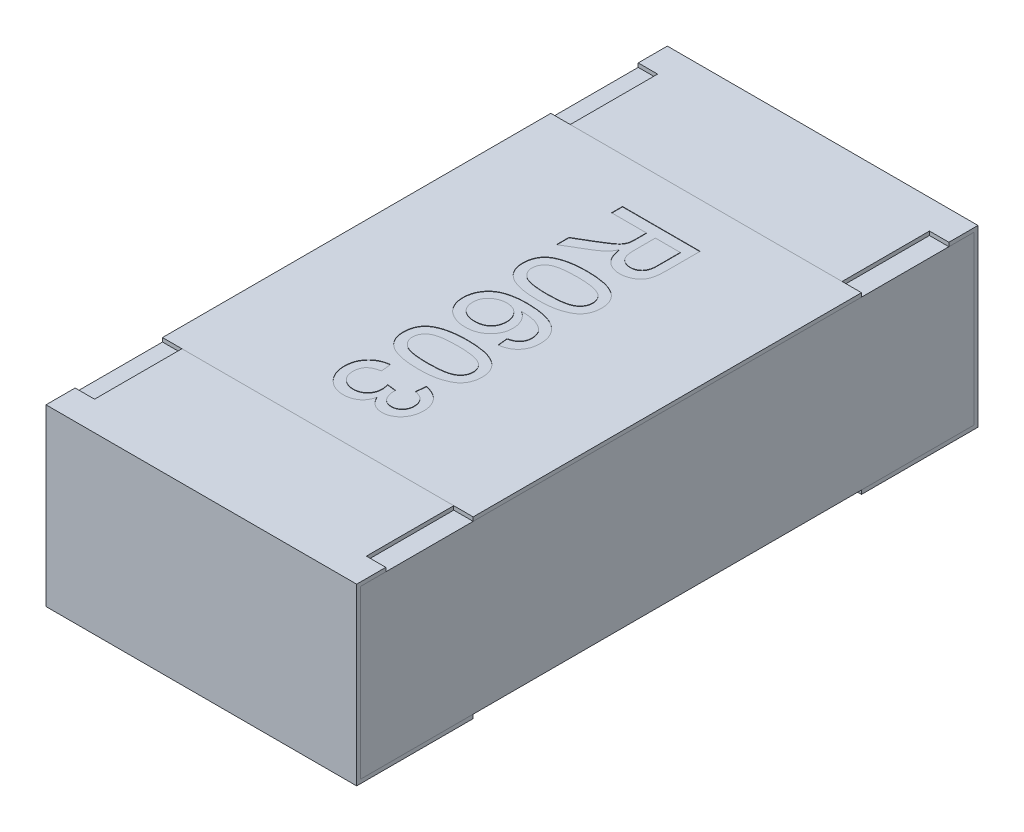
from build123d import *

# Parameters (mm, degrees)
BOSS_EXTRUDE2_DEPTH   = 0.4
BOSS_EXTRUDE2_2_DEPTH = 0.4
BOSS_EXTRUDE3_START   = -0.4
SKETCH5_W             = 1.58
SKETCH5_H             = 0.43
BOSS_EXTRUDE3_DEPTH   = 0.8
SKETCH6_W             = 0.05
SKETCH6_H             = 0.225
CUT_EXTRUDE1_DEPTH    = 0.01
SKETCH7_W             = 0.8
SKETCH7_H             = 1
BOSS_EXTRUDE4_DEPTH   = 0.01
TEXT0603_DEPTH        = 0.001


with BuildPart() as part:
    # Sketch4 → Boss-Extrude2 (new body, symmetric)
    with BuildSketch(Plane(origin=(0, 0, 0), x_dir=(0, 0, -1), z_dir=(1, 0, 0))):
        Polygon((-0.8, 0.225), (-0.8, -0.225), (-0.5, -0.225), (-0.5, -0.215), (-0.79, -0.215), (-0.79, 0.215), (-0.5, 0.215), (-0.5, 0.225), align=None)
    extrude(amount=BOSS_EXTRUDE2_DEPTH, both=True)


with BuildPart() as body_2:
    # Sketch4 → Boss-Extrude2 2 (new body, symmetric)
    with BuildSketch(Plane(origin=(0, 0, 0), x_dir=(0, 0, -1), z_dir=(1, 0, 0))):
        Polygon((0.5, 0.225), (0.8, 0.225), (0.8, -0.225), (0.5, -0.225), (0.5, -0.215), (0.79, -0.215), (0.79, 0.215), (0.5, 0.215), align=None)
    extrude(amount=BOSS_EXTRUDE2_2_DEPTH, both=True)


with BuildPart() as body_3:
    # Sketch5 → Boss-Extrude3 (new body)
    with BuildSketch(Plane(origin=(0, 0, 0), x_dir=(0, 0, -1), z_dir=(1, 0, 0)).offset(BOSS_EXTRUDE3_START)):
        Rectangle(SKETCH5_W, SKETCH5_H)
    extrude(amount=BOSS_EXTRUDE3_DEPTH)


with BuildPart() as cut_extrude1_tool:
    # Sketch6 → Cut-Extrude1 (new body)
    with BuildSketch(Plane(origin=(0, 0.225, 0), x_dir=(1, 0, 0), z_dir=(0, 1, 0))):
        with Locations((-0.375, 0.6125)):
            Rectangle(SKETCH6_W, SKETCH6_H)
        with Locations((0.375, 0.6125)):
            Rectangle(SKETCH6_W, SKETCH6_H)
        with Locations((0.375, -0.6125)):
            Rectangle(SKETCH6_W, SKETCH6_H)
        with Locations((-0.375, -0.6125)):
            Rectangle(SKETCH6_W, SKETCH6_H)
    extrude(amount=-CUT_EXTRUDE1_DEPTH)


with BuildPart() as part_1:
    add(part.part)

    # Cut-Extrude1: cut by cut_extrude1_tool
    add(cut_extrude1_tool.part, mode=Mode.SUBTRACT)


with BuildPart() as body_2_1:
    add(body_2.part)

    # Cut-Extrude1: cut by cut_extrude1_tool
    add(cut_extrude1_tool.part, mode=Mode.SUBTRACT)


with BuildPart() as body_4:
    # Sketch7 → Boss-Extrude4 (new body)
    with BuildSketch(Plane(origin=(0, 0.215, 0), x_dir=(1, 0, 0), z_dir=(0, 1, 0))):
        Rectangle(SKETCH7_W, SKETCH7_H)
    extrude(amount=BOSS_EXTRUDE4_DEPTH)

    # Sketch10 → TEXT0603 (cut)
    with BuildSketch(Plane(origin=(0, 0.225, 0), x_dir=(1, 0, 0), z_dir=(0, 1, 0))):
        with BuildLine():
            Line((-0.1, 0.384615385), (0.1, 0.384615385))
            Line((0.1, 0.384615385), (0.1, 0.297836538))
            add(Edge.make_bspline(
                [(0.1, 0.297836538), (0.099984065, 0.295793153), (0.099953225, 0.291838418), (0.09973285, 0.286103396), (0.099264662, 0.280762976), (0.098741754, 0.2757835), (0.09796967, 0.27117349), (0.097063877, 0.266930747), (0.095993333, 0.263071546), (0.094727909, 0.259566517), (0.09329673, 0.256314363), (0.09152995, 0.253300671), (0.089597129, 0.250396276), (0.087307981, 0.247716073), (0.084846527, 0.245142742), (0.082091084, 0.242764219), (0.079080565, 0.240568895), (0.074776604, 0.237860062), (0.069015312, 0.235009752), (0.061680333, 0.232577019), (0.053991505, 0.231021652), (0.048738791, 0.230854194), (0.046073718, 0.230769231)],
                knots=[0, 0, 0, 0, 6.13e-06, 1.1865e-05, 1.7211e-05, 2.2211e-05, 2.6881e-05, 3.1226e-05, 3.5222e-05, 3.8884e-05, 4.2399e-05, 4.5862e-05, 4.9352e-05, 5.285e-05, 5.642e-05, 6.0027e-05, 6.3753e-05, 6.7588e-05, 7.5275e-05, 8.2965e-05, 9.072e-05, 9.8707e-05, 9.8707e-05, 9.8707e-05, 9.8707e-05], degree=3))
            add(Edge.make_bspline(
                [(0.046073718, 0.230769231), (0.044362886, 0.230808368), (0.040983876, 0.230885665), (0.036015821, 0.231477767), (0.031269065, 0.232549148), (0.026701941, 0.23392291), (0.022379506, 0.235803447), (0.018212175, 0.237980986), (0.014319265, 0.240682401), (0.010571159, 0.243698869), (0.007135151, 0.247205721), (0.00396506, 0.251109408), (0.001226184, 0.25550818), (-0.001235186, 0.260321091), (-0.003389054, 0.265556874), (-0.005200005, 0.271250346), (-0.006617793, 0.277381347), (-0.007327988, 0.281633046), (-0.007692308, 0.283814103)],
                knots=[0, 0, 0, 0, 5.132e-06, 1.0136e-05, 1.4977e-05, 1.9717e-05, 2.442e-05, 2.9098e-05, 3.3798e-05, 3.861e-05, 4.3511e-05, 4.8498e-05, 5.3667e-05, 5.9024e-05, 6.4701e-05, 7.0631e-05, 7.6928e-05, 8.3561e-05, 8.3561e-05, 8.3561e-05, 8.3561e-05], degree=3))
            add(Edge.make_bspline(
                [(-0.007692308, 0.283814103), (-0.008502515, 0.282201955), (-0.010035947, 0.279150736), (-0.012497756, 0.274942107), (-0.014933997, 0.271328075), (-0.016715461, 0.26924351), (-0.017548077, 0.268269231)],
                knots=[0, 0, 0, 0, 5.411e-06, 1.0242e-05, 1.4621e-05, 1.8463e-05, 1.8463e-05, 1.8463e-05, 1.8463e-05], degree=3))
            add(Edge.make_bspline(
                [(-0.017548077, 0.268269231), (-0.019397609, 0.266376698), (-0.023190694, 0.262495425), (-0.029711346, 0.257198922), (-0.036882196, 0.251958094), (-0.042107727, 0.248811611), (-0.044791667, 0.247195513)],
                knots=[0, 0, 0, 0, 7.932e-06, 1.6268e-05, 2.5164e-05, 3.4558e-05, 3.4558e-05, 3.4558e-05, 3.4558e-05], degree=3))
            Line((-0.044791667, 0.247195513), (-0.1, 0.214383013))
            Line((-0.1, 0.214383013), (-0.1, 0.246714744))
            Line((-0.1, 0.246714744), (-0.057772436, 0.271634615))
            add(Edge.make_bspline(
                [(-0.057772436, 0.271634615), (-0.056290856, 0.272530646), (-0.053419797, 0.274267005), (-0.049226345, 0.27677451), (-0.045367087, 0.27923526), (-0.041725057, 0.281510108), (-0.03839495, 0.283720739), (-0.035277423, 0.285743012), (-0.032495712, 0.287732518), (-0.029145459, 0.29004634), (-0.025498969, 0.292835986), (-0.02177642, 0.296113346), (-0.018736859, 0.29915438), (-0.015800487, 0.302959128), (-0.013064385, 0.307680303), (-0.011792823, 0.311685061), (-0.011177885, 0.313621795)],
                knots=[0, 0, 0, 0, 5.194e-06, 1.0066e-05, 1.4657e-05, 1.8925e-05, 2.2947e-05, 2.6648e-05, 3.0071e-05, 3.3206e-05, 3.8863e-05, 4.383e-05, 4.808e-05, 5.1735e-05, 5.823e-05, 6.4312e-05, 6.4312e-05, 6.4312e-05, 6.4312e-05], degree=3))
            add(Edge.make_bspline(
                [(-0.011177885, 0.313621795), (-0.011031283, 0.314434737), (-0.010696589, 0.316290709), (-0.010477999, 0.319442145), (-0.010245995, 0.323260496), (-0.010252755, 0.32602772), (-0.01025641, 0.327524038)],
                knots=[0, 0, 0, 0, 2.477e-06, 5.654e-06, 9.465e-06, 1.3953e-05, 1.3953e-05, 1.3953e-05, 1.3953e-05], degree=3))
            Line((-0.01025641, 0.327524038), (-0.01025641, 0.356410256))
            Line((-0.01025641, 0.356410256), (-0.1, 0.356410256))
            Line((-0.1, 0.356410256), (-0.1, 0.384615385))
        make_face()
        with BuildLine():
            Line((0.012820513, 0.356410256), (0.012820513, 0.302844551))
            add(Edge.make_bspline(
                [(0.012820513, 0.302844551), (0.012862706, 0.300158599), (0.012941582, 0.295137464), (0.013610378, 0.288115682), (0.014684826, 0.282120684), (0.01622688, 0.277040573), (0.01837747, 0.272774838), (0.021049498, 0.269110171), (0.024300639, 0.26599257), (0.028039024, 0.26344463), (0.032117992, 0.261437809), (0.036432982, 0.260067832), (0.04089065, 0.259113377), (0.04393186, 0.259021109), (0.045472756, 0.258974359)],
                knots=[0, 0, 0, 0, 8.056e-06, 1.5061e-05, 2.1135e-05, 2.6305e-05, 3.0927e-05, 3.5399e-05, 3.9847e-05, 4.437e-05, 4.8921e-05, 5.3432e-05, 5.7926e-05, 6.2542e-05, 6.2542e-05, 6.2542e-05, 6.2542e-05], degree=3))
            add(Edge.make_bspline(
                [(0.045472756, 0.258974359), (0.046595386, 0.259011584), (0.048794286, 0.259084498), (0.052021662, 0.259466736), (0.055088415, 0.260209898), (0.058010756, 0.261191241), (0.060767282, 0.262502515), (0.063379352, 0.264060255), (0.065832489, 0.265919119), (0.068134166, 0.268048342), (0.070228467, 0.270493076), (0.072035395, 0.273285537), (0.073570893, 0.276403701), (0.074789568, 0.279851192), (0.075764309, 0.283617151), (0.076412773, 0.287723015), (0.076881999, 0.292150008), (0.076909128, 0.295217658), (0.076923077, 0.296794872)],
                knots=[0, 0, 0, 0, 3.369e-06, 6.599e-06, 9.728e-06, 1.282e-05, 1.5831e-05, 1.8868e-05, 2.1929e-05, 2.5047e-05, 2.8258e-05, 3.1559e-05, 3.4999e-05, 3.8661e-05, 4.2509e-05, 4.6652e-05, 5.1121e-05, 5.585e-05, 5.585e-05, 5.585e-05, 5.585e-05], degree=3))
            Line((0.076923077, 0.296794872), (0.076923077, 0.356410256))
            Line((0.076923077, 0.356410256), (0.012820513, 0.356410256))
        make_face(mode=Mode.SUBTRACT)
        with BuildLine():
            add(Edge.make_bspline(
                [(-0.001362179, 0.194871795), (0.001496004, 0.194845962), (0.007093982, 0.194795365), (0.01528483, 0.194481531), (0.023063338, 0.1939336), (0.030422754, 0.193115695), (0.03737968, 0.192147128), (0.043924224, 0.190888035), (0.050070943, 0.189471208), (0.055813865, 0.187771845), (0.061200859, 0.185902848), (0.066228535, 0.183789277), (0.070867156, 0.181390323), (0.075242692, 0.178922309), (0.079150183, 0.17604891), (0.082837127, 0.173134938), (0.086093066, 0.169882364), (0.089024575, 0.166445884), (0.091610645, 0.162768544), (0.093842323, 0.158871465), (0.095812677, 0.1547692), (0.097295972, 0.150383684), (0.098505168, 0.145805926), (0.099394669, 0.1410007), (0.099919059, 0.135962707), (0.099972715, 0.132519946), (0.1, 0.130769231)],
                knots=[0, 0, 0, 0, 8.575e-06, 1.6794e-05, 2.4587e-05, 3.1962e-05, 3.9005e-05, 4.5652e-05, 5.1949e-05, 5.7921e-05, 6.361e-05, 6.9049e-05, 7.4263e-05, 7.9273e-05, 8.4098e-05, 8.8797e-05, 9.3358e-05, 9.7877e-05, 0.000102335, 0.000106822, 0.000111338, 0.000115963, 0.000120686, 0.000125534, 0.000130609, 0.00013586, 0.00013586, 0.00013586, 0.00013586], degree=3))
            add(Edge.make_bspline(
                [(0.1, 0.130769231), (0.09992442, 0.128200749), (0.099775939, 0.123154864), (0.098566996, 0.115787062), (0.096493798, 0.108846366), (0.093718792, 0.102333863), (0.090129104, 0.096390371), (0.085877537, 0.091016901), (0.080786087, 0.086430566), (0.07502184, 0.082479866), (0.068573352, 0.079092141), (0.061501351, 0.076061682), (0.053775857, 0.073344593), (0.046880048, 0.071355802), (0.040917257, 0.069961484), (0.035990018, 0.069112583), (0.030689821, 0.068328803), (0.025003973, 0.067773248), (0.01895905, 0.067207926), (0.012528692, 0.06692882), (0.005717266, 0.06671582), (0.001041875, 0.066683358), (-0.001362179, 0.066666667)],
                knots=[0, 0, 0, 0, 7.703e-06, 1.5132e-05, 2.232e-05, 2.939e-05, 3.6309e-05, 4.3092e-05, 4.987e-05, 5.6782e-05, 6.4006e-05, 7.1686e-05, 7.9847e-05, 8.8558e-05, 9.3204e-05, 9.821e-05, 0.000103553, 0.000109274, 0.000115346, 0.000121764, 0.000128578, 0.00013579, 0.00013579, 0.00013579, 0.00013579], degree=3))
            add(Edge.make_bspline(
                [(-0.001362179, 0.066666667), (-0.00420696, 0.066692838), (-0.009764799, 0.06674397), (-0.017889658, 0.067051418), (-0.02561058, 0.067625242), (-0.032936981, 0.068364698), (-0.039875654, 0.069360281), (-0.046409619, 0.070604646), (-0.052546889, 0.07204189), (-0.058293654, 0.073668328), (-0.063657824, 0.07556057), (-0.06866507, 0.07769477), (-0.073364456, 0.079983262), (-0.07766846, 0.082579034), (-0.081648328, 0.085343686), (-0.085316591, 0.088303046), (-0.088621112, 0.091518412), (-0.09154299, 0.094986969), (-0.094175564, 0.098638059), (-0.096427535, 0.102545265), (-0.098306244, 0.106699448), (-0.099876447, 0.111063583), (-0.10106977, 0.115666638), (-0.10195578, 0.120484629), (-0.102484984, 0.125548988), (-0.102537366, 0.129005142), (-0.102564103, 0.130769231)],
                knots=[0, 0, 0, 0, 8.535e-06, 1.6674e-05, 2.4387e-05, 3.1758e-05, 3.8761e-05, 4.5408e-05, 5.1705e-05, 5.7665e-05, 6.3317e-05, 6.8757e-05, 7.3988e-05, 7.8984e-05, 8.3818e-05, 8.8517e-05, 9.3107e-05, 9.7627e-05, 0.000102107, 0.000106594, 0.00011113, 0.000115768, 0.000120491, 0.000125379, 0.000130454, 0.000135745, 0.000135745, 0.000135745, 0.000135745], degree=3))
            add(Edge.make_bspline(
                [(-0.102564103, 0.130769231), (-0.102498128, 0.133082104), (-0.102369495, 0.13759157), (-0.101495515, 0.144177313), (-0.099957268, 0.150358384), (-0.097894263, 0.156186917), (-0.095134874, 0.161597397), (-0.091777539, 0.166615658), (-0.087900369, 0.171342538), (-0.084841372, 0.174063617), (-0.083293269, 0.175440705)],
                knots=[0, 0, 0, 0, 6.938e-06, 1.3528e-05, 1.9883e-05, 2.6017e-05, 3.2037e-05, 3.8049e-05, 4.4107e-05, 5.0314e-05, 5.0314e-05, 5.0314e-05, 5.0314e-05], degree=3))
            add(Edge.make_bspline(
                [(-0.083293269, 0.175440705), (-0.081006797, 0.177025765), (-0.076291993, 0.180294227), (-0.068252815, 0.184119678), (-0.059402809, 0.187532048), (-0.049568339, 0.190210132), (-0.038827676, 0.19230774), (-0.027159744, 0.193822737), (-0.014569584, 0.194680076), (-0.005864031, 0.194806446), (-0.001362179, 0.194871795)],
                knots=[0, 0, 0, 0, 8.334e-06, 1.7185e-05, 2.662e-05, 3.6768e-05, 4.7713e-05, 5.9431e-05, 7.2042e-05, 8.5548e-05, 8.5548e-05, 8.5548e-05, 8.5548e-05], degree=3))
        make_face()
        with BuildLine():
            add(Edge.make_bspline(
                [(-0.001282051, 0.169230769), (-0.005128779, 0.16920531), (-0.012492266, 0.169156575), (-0.023012278, 0.168647411), (-0.032502764, 0.167770907), (-0.040950586, 0.166612111), (-0.048367169, 0.165082031), (-0.054733615, 0.163160835), (-0.060126334, 0.16099519), (-0.064478489, 0.158315246), (-0.06802613, 0.155381002), (-0.071077216, 0.152351597), (-0.07367057, 0.149155757), (-0.075832898, 0.145814337), (-0.07747007, 0.14227549), (-0.078656697, 0.138577914), (-0.079339582, 0.134720804), (-0.0794377, 0.132093937), (-0.079487179, 0.130769231)],
                knots=[0, 0, 0, 0, 1.154e-05, 2.2089e-05, 3.1585e-05, 4.0124e-05, 4.766e-05, 5.4275e-05, 6.0057e-05, 6.5039e-05, 6.9538e-05, 7.3844e-05, 7.7917e-05, 8.1862e-05, 8.5752e-05, 8.9578e-05, 9.3484e-05, 9.7458e-05, 9.7458e-05, 9.7458e-05, 9.7458e-05], degree=3))
            add(Edge.make_bspline(
                [(-0.079487179, 0.130769231), (-0.079436618, 0.129444856), (-0.079336357, 0.126818647), (-0.07866853, 0.122952625), (-0.077420817, 0.119269435), (-0.075789427, 0.115735865), (-0.073676385, 0.112370158), (-0.071073236, 0.109190014), (-0.068023961, 0.10614465), (-0.064435085, 0.103223588), (-0.060062809, 0.10056406), (-0.054674482, 0.098357791), (-0.048296887, 0.096466535), (-0.040884082, 0.09492806), (-0.032449618, 0.093764484), (-0.022985453, 0.092893279), (-0.012478977, 0.092380708), (-0.005128796, 0.092332777), (-0.001282051, 0.092307692)],
                knots=[0, 0, 0, 0, 3.974e-06, 7.88e-06, 1.1718e-05, 1.5608e-05, 1.9532e-05, 2.3605e-05, 2.7911e-05, 3.2442e-05, 3.7457e-05, 4.3202e-05, 4.9856e-05, 5.7392e-05, 6.5891e-05, 7.5387e-05, 8.5897e-05, 9.7436e-05, 9.7436e-05, 9.7436e-05, 9.7436e-05], degree=3))
            add(Edge.make_bspline(
                [(-0.001282051, 0.092307692), (0.002484656, 0.092331974), (0.009701523, 0.092378496), (0.020018863, 0.092904291), (0.029350069, 0.093728239), (0.037703671, 0.09485533), (0.045070832, 0.096353044), (0.051466511, 0.098170142), (0.056879301, 0.100333723), (0.06135668, 0.102911645), (0.065052608, 0.105769962), (0.068189367, 0.10880685), (0.070938214, 0.11196354), (0.073090618, 0.115420423), (0.0748559, 0.119030542), (0.076037637, 0.122871286), (0.076796066, 0.126893063), (0.076880121, 0.129643876), (0.076923077, 0.131049679)],
                knots=[0, 0, 0, 0, 1.1299e-05, 2.1649e-05, 3.0982e-05, 3.9396e-05, 4.6923e-05, 5.3516e-05, 5.9319e-05, 6.4363e-05, 6.8963e-05, 7.3298e-05, 7.7448e-05, 8.1483e-05, 8.5479e-05, 8.947e-05, 9.3502e-05, 9.7715e-05, 9.7715e-05, 9.7715e-05, 9.7715e-05], degree=3))
            add(Edge.make_bspline(
                [(0.076923077, 0.131049679), (0.076888311, 0.132374303), (0.076819756, 0.134986291), (0.076165406, 0.138810583), (0.075071185, 0.142434819), (0.073588958, 0.145900523), (0.071594172, 0.149121173), (0.069265118, 0.152224494), (0.066427425, 0.155065137), (0.064306011, 0.156776884), (0.063221154, 0.157652244)],
                knots=[0, 0, 0, 0, 3.971e-06, 7.831e-06, 1.1596e-05, 1.531e-05, 1.9103e-05, 2.2933e-05, 2.6927e-05, 3.1108e-05, 3.1108e-05, 3.1108e-05, 3.1108e-05], degree=3))
            add(Edge.make_bspline(
                [(0.063221154, 0.157652244), (0.061627835, 0.158605243), (0.058263081, 0.160617777), (0.052415001, 0.162869686), (0.045731758, 0.164858932), (0.038110526, 0.166496742), (0.029564378, 0.167681583), (0.02010324, 0.168616969), (0.009713902, 0.169102867), (0.002484394, 0.169186959), (-0.001282051, 0.169230769)],
                knots=[0, 0, 0, 0, 5.561e-06, 1.1743e-05, 1.8727e-05, 2.6476e-05, 3.5099e-05, 4.4599e-05, 5.4989e-05, 6.6289e-05, 6.6289e-05, 6.6289e-05, 6.6289e-05], degree=3))
        make_face(mode=Mode.SUBTRACT)
        with BuildLine():
            Line((0.048717949, -0.084615385), (0.046153846, -0.058974359))
            add(Edge.make_bspline(
                [(0.046153846, -0.058974359), (0.048359111, -0.058421046), (0.052510183, -0.05737952), (0.058140486, -0.05519545), (0.062902765, -0.052788651), (0.06546712, -0.050697666), (0.066666667, -0.049719551)],
                knots=[0, 0, 0, 0, 6.813e-06, 1.2825e-05, 1.8095e-05, 2.2726e-05, 2.2726e-05, 2.2726e-05, 2.2726e-05], degree=3))
            add(Edge.make_bspline(
                [(0.066666667, -0.049719551), (0.067484823, -0.048879954), (0.069093948, -0.047228659), (0.071191453, -0.044517835), (0.072968565, -0.041660177), (0.074408295, -0.03864705), (0.075545599, -0.03549473), (0.076341204, -0.032190161), (0.076833728, -0.028740829), (0.07689304, -0.026390539), (0.076923077, -0.025200321)],
                knots=[0, 0, 0, 0, 3.515e-06, 6.913e-06, 1.0259e-05, 1.3592e-05, 1.6912e-05, 2.0294e-05, 2.3773e-05, 2.7342e-05, 2.7342e-05, 2.7342e-05, 2.7342e-05], degree=3))
            add(Edge.make_bspline(
                [(0.076923077, -0.025200321), (0.076860948, -0.023270771), (0.076738183, -0.019458065), (0.075536329, -0.013864144), (0.073737563, -0.008430875), (0.071914142, -0.005064763), (0.07099359, -0.003365385)],
                knots=[0, 0, 0, 0, 5.78e-06, 1.1422e-05, 1.7098e-05, 2.2885e-05, 2.2885e-05, 2.2885e-05, 2.2885e-05], degree=3))
            add(Edge.make_bspline(
                [(0.07099359, -0.003365385), (0.069608433, -0.001694921), (0.066765039, 0.001734141), (0.061526643, 0.006218952), (0.055384929, 0.010167592), (0.049693495, 0.013137648), (0.044564387, 0.015197564), (0.040193981, 0.016605967), (0.035337576, 0.017736114), (0.030042438, 0.018698432), (0.02429006, 0.01943658), (0.018079873, 0.020055469), (0.011395209, 0.020397333), (0.00678452, 0.02047353), (0.004407051, 0.020512821)],
                knots=[0, 0, 0, 0, 6.501e-06, 1.3346e-05, 2.058e-05, 2.8374e-05, 3.2563e-05, 3.7149e-05, 4.2134e-05, 4.751e-05, 5.3289e-05, 5.9528e-05, 6.6229e-05, 7.3362e-05, 7.3362e-05, 7.3362e-05, 7.3362e-05], degree=3))
            add(Edge.make_bspline(
                [(0.004407051, 0.020512821), (0.006530318, 0.019000607), (0.010686742, 0.016040357), (0.01614183, 0.010819847), (0.02071144, 0.005084054), (0.024398078, -0.00110391), (0.02723058, -0.007607341), (0.029293949, -0.014281773), (0.030542464, -0.021133796), (0.030693258, -0.025756108), (0.030769231, -0.028084936)],
                knots=[0, 0, 0, 0, 7.813e-06, 1.5293e-05, 2.2564e-05, 2.9751e-05, 3.6837e-05, 4.3795e-05, 5.0672e-05, 5.7654e-05, 5.7654e-05, 5.7654e-05, 5.7654e-05], degree=3))
            add(Edge.make_bspline(
                [(0.030769231, -0.028084936), (0.030715427, -0.030090799), (0.030609129, -0.034053762), (0.02976185, -0.039888548), (0.028295929, -0.045474614), (0.026340359, -0.050863965), (0.02374514, -0.055985291), (0.020657985, -0.06092552), (0.016921948, -0.065574916), (0.012720699, -0.069995691), (0.008050779, -0.074021015), (0.003024369, -0.077583611), (-0.002370284, -0.080552475), (-0.008097131, -0.082959874), (-0.014135312, -0.084844086), (-0.020501978, -0.08621319), (-0.027209712, -0.087014645), (-0.031795387, -0.087123804), (-0.034134615, -0.087179487)],
                knots=[0, 0, 0, 0, 6.016e-06, 1.1886e-05, 1.7639e-05, 2.3317e-05, 2.9051e-05, 3.4831e-05, 4.0762e-05, 4.6912e-05, 5.3104e-05, 5.9229e-05, 6.5361e-05, 7.1538e-05, 7.7835e-05, 8.431e-05, 9.1049e-05, 9.8066e-05, 9.8066e-05, 9.8066e-05, 9.8066e-05], degree=3))
            add(Edge.make_bspline(
                [(-0.034134615, -0.087179487), (-0.037225822, -0.087079181), (-0.043326243, -0.08688123), (-0.052314529, -0.085308752), (-0.060955133, -0.082734359), (-0.067859389, -0.079780267), (-0.073059929, -0.076897172), (-0.076770639, -0.074581621), (-0.080223556, -0.072033619), (-0.083480916, -0.069336406), (-0.086434847, -0.066372376), (-0.089231066, -0.063311543), (-0.091706494, -0.059983919), (-0.094001953, -0.056524377), (-0.095987699, -0.052862187), (-0.097765603, -0.04909954), (-0.099251567, -0.045201524), (-0.100443275, -0.041178578), (-0.101418915, -0.037048746), (-0.102091513, -0.032790467), (-0.102505878, -0.028413815), (-0.102544544, -0.025454993), (-0.102564103, -0.023958333)],
                knots=[0, 0, 0, 0, 9.269e-06, 1.8293e-05, 2.728e-05, 3.6271e-05, 4.0754e-05, 4.5111e-05, 4.9382e-05, 5.3619e-05, 5.7784e-05, 6.1926e-05, 6.6045e-05, 7.0212e-05, 7.4372e-05, 7.853e-05, 8.2689e-05, 8.6872e-05, 9.1109e-05, 9.541e-05, 9.9796e-05, 0.000104284, 0.000104284, 0.000104284, 0.000104284], degree=3))
            add(Edge.make_bspline(
                [(-0.102564103, -0.023958333), (-0.102493836, -0.021430821), (-0.102356031, -0.016473925), (-0.101302468, -0.009217573), (-0.099525544, -0.002319832), (-0.09708891, 0.004231312), (-0.093939935, 0.010421704), (-0.090050422, 0.016229874), (-0.0854685, 0.021680817), (-0.080191835, 0.026782237), (-0.074080908, 0.031390674), (-0.067078821, 0.035408183), (-0.059127448, 0.038698939), (-0.050326016, 0.041478382), (-0.040591263, 0.043536221), (-0.029986068, 0.045123263), (-0.018469558, 0.045958003), (-0.010497956, 0.046087033), (-0.006370192, 0.046153846)],
                knots=[0, 0, 0, 0, 7.581e-06, 1.4867e-05, 2.1941e-05, 2.8914e-05, 3.5794e-05, 4.2728e-05, 4.9838e-05, 5.712e-05, 6.47e-05, 7.2741e-05, 8.1268e-05, 9.0467e-05, 0.000100393, 0.000111084, 0.000122617, 0.000135001, 0.000135001, 0.000135001, 0.000135001], degree=3))
            add(Edge.make_bspline(
                [(-0.006370192, 0.046153846), (-0.004019623, 0.046137728), (0.000615996, 0.046105942), (0.007444259, 0.045877004), (0.014029427, 0.045425592), (0.020362913, 0.044832248), (0.026454856, 0.044067754), (0.032301308, 0.043170361), (0.037894086, 0.04202542), (0.043245545, 0.040765654), (0.048359359, 0.03930423), (0.05324198, 0.03773375), (0.057857633, 0.035911062), (0.062234282, 0.033954783), (0.066365516, 0.03182602), (0.070267214, 0.029559737), (0.073889326, 0.027054554), (0.076158046, 0.025252867), (0.077283654, 0.024358974)],
                knots=[0, 0, 0, 0, 7.052e-06, 1.3907e-05, 2.0492e-05, 2.6851e-05, 3.2988e-05, 3.8909e-05, 4.459e-05, 5.011e-05, 5.5398e-05, 6.0542e-05, 6.549e-05, 7.0278e-05, 7.4919e-05, 7.9426e-05, 8.3805e-05, 8.8116e-05, 8.8116e-05, 8.8116e-05, 8.8116e-05], degree=3))
            add(Edge.make_bspline(
                [(0.077283654, 0.024358974), (0.079100398, 0.022743808), (0.082681369, 0.019560165), (0.087307136, 0.014113952), (0.091258253, 0.008310554), (0.094450413, 0.002057413), (0.096939124, -0.004597678), (0.098745707, -0.011658891), (0.099793401, -0.01914593), (0.099930017, -0.024262183), (0.1, -0.026883013)],
                knots=[0, 0, 0, 0, 7.285e-06, 1.436e-05, 2.1371e-05, 2.8306e-05, 3.5368e-05, 4.2646e-05, 5.013e-05, 5.7991e-05, 5.7991e-05, 5.7991e-05, 5.7991e-05], degree=3))
            add(Edge.make_bspline(
                [(0.1, -0.026883013), (0.099965504, -0.028834512), (0.099897732, -0.032668388), (0.099247462, -0.038285996), (0.098160632, -0.043629327), (0.096694621, -0.048710285), (0.094743172, -0.053499323), (0.092430494, -0.058051654), (0.089648488, -0.062321053), (0.086435162, -0.066276611), (0.082881605, -0.069928126), (0.078957976, -0.073198737), (0.074713177, -0.076076121), (0.07013838, -0.078582779), (0.065255241, -0.080696313), (0.060042771, -0.082431628), (0.054502312, -0.083750584), (0.050672796, -0.084323122), (0.048717949, -0.084615385)],
                knots=[0, 0, 0, 0, 5.853e-06, 1.1498e-05, 1.6935e-05, 2.2197e-05, 2.7338e-05, 3.2426e-05, 3.7494e-05, 4.2593e-05, 4.7693e-05, 5.2756e-05, 5.789e-05, 6.3054e-05, 6.8383e-05, 7.383e-05, 7.9515e-05, 8.5443e-05, 8.5443e-05, 8.5443e-05, 8.5443e-05], degree=3))
        make_face()
        with BuildLine():
            add(Edge.make_bspline(
                [(-0.033613782, 0.020512821), (-0.035621463, 0.020441501), (-0.039610467, 0.020299798), (-0.045531459, 0.019215934), (-0.051308467, 0.017445908), (-0.056877331, 0.015020066), (-0.06205137, 0.012024599), (-0.066635926, 0.008466682), (-0.070563686, 0.004423543), (-0.073843173, -8.3089e-05), (-0.076363368, -0.005042634), (-0.078188645, -0.010366268), (-0.079291848, -0.01606035), (-0.079421086, -0.019987031), (-0.079487179, -0.021995192)],
                knots=[0, 0, 0, 0, 6.02e-06, 1.1962e-05, 1.7994e-05, 2.4113e-05, 3.0146e-05, 3.5884e-05, 4.1465e-05, 4.7003e-05, 5.254e-05, 5.8089e-05, 6.3841e-05, 6.9861e-05, 6.9861e-05, 6.9861e-05, 6.9861e-05], degree=3))
            add(Edge.make_bspline(
                [(-0.079487179, -0.021995192), (-0.079448651, -0.023426303), (-0.079373447, -0.026219706), (-0.078785619, -0.030308561), (-0.07789718, -0.03420187), (-0.076537411, -0.037881357), (-0.074872898, -0.041372647), (-0.072792366, -0.044658358), (-0.070354139, -0.047739385), (-0.067542866, -0.050582486), (-0.064417088, -0.053152372), (-0.060994979, -0.055385173), (-0.057333114, -0.057356969), (-0.05334143, -0.058840069), (-0.049122211, -0.060048582), (-0.044635557, -0.06093707), (-0.039876317, -0.061458706), (-0.036606553, -0.061511491), (-0.034935897, -0.061538462)],
                knots=[0, 0, 0, 0, 4.292e-06, 8.377e-06, 1.2371e-05, 1.6249e-05, 2.0119e-05, 2.3954e-05, 2.789e-05, 3.1884e-05, 3.5927e-05, 4.0005e-05, 4.4127e-05, 4.8375e-05, 5.275e-05, 5.7284e-05, 6.208e-05, 6.7091e-05, 6.7091e-05, 6.7091e-05, 6.7091e-05], degree=3))
            add(Edge.make_bspline(
                [(-0.034935897, -0.061538462), (-0.033331604, -0.061513423), (-0.030194205, -0.061464458), (-0.02561586, -0.060914351), (-0.021288496, -0.060111308), (-0.01724491, -0.05888449), (-0.013460922, -0.057361304), (-0.00991239, -0.055525518), (-0.006642246, -0.053308791), (-0.00368572, -0.050726886), (-0.000997124, -0.047896591), (0.001355177, -0.044786146), (0.003304847, -0.041411682), (0.004934509, -0.037806986), (0.00617072, -0.033946808), (0.007029815, -0.029836971), (0.00762883, -0.025498263), (0.007670824, -0.022518165), (0.007692308, -0.02099359)],
                knots=[0, 0, 0, 0, 4.81e-06, 9.407e-06, 1.3815e-05, 1.7998e-05, 2.206e-05, 2.6038e-05, 2.9961e-05, 3.3881e-05, 3.7792e-05, 4.1654e-05, 4.555e-05, 4.9459e-05, 5.3501e-05, 5.7682e-05, 6.2045e-05, 6.6615e-05, 6.6615e-05, 6.6615e-05, 6.6615e-05], degree=3))
            add(Edge.make_bspline(
                [(0.007692308, -0.02099359), (0.007670171, -0.019575715), (0.007626548, -0.016781659), (0.007022434, -0.012684324), (0.006163151, -0.008734664), (0.004908687, -0.004951548), (0.003313336, -0.001332854), (0.001312084, 0.002099412), (-0.000996721, 0.005391636), (-0.003691508, 0.0084553), (-0.006612301, 0.011291533), (-0.009812536, 0.013761912), (-0.013231501, 0.015841857), (-0.016867826, 0.01760136), (-0.020749697, 0.018902053), (-0.024844946, 0.019823792), (-0.029150562, 0.020396178), (-0.032102895, 0.020473335), (-0.033613782, 0.020512821)],
                knots=[0, 0, 0, 0, 4.25e-06, 8.375e-06, 1.2399e-05, 1.6364e-05, 2.031e-05, 2.4241e-05, 2.8265e-05, 3.2354e-05, 3.6463e-05, 4.0462e-05, 4.4454e-05, 4.845e-05, 5.2555e-05, 5.6705e-05, 6.1028e-05, 6.556e-05, 6.556e-05, 6.556e-05, 6.556e-05], degree=3))
        make_face(mode=Mode.SUBTRACT)
        with BuildLine():
            add(Edge.make_bspline(
                [(-0.001362179, -0.112820513), (0.001496004, -0.112846346), (0.007093982, -0.112896943), (0.01528483, -0.113210777), (0.023063338, -0.113758708), (0.030422754, -0.114576612), (0.03737968, -0.115545179), (0.043924224, -0.116804273), (0.050070943, -0.1182211), (0.055813865, -0.119920462), (0.061200859, -0.12178946), (0.066228535, -0.123903031), (0.070867156, -0.126301985), (0.075242692, -0.128769998), (0.079150183, -0.131643397), (0.082837127, -0.13455737), (0.086093066, -0.137809943), (0.089024575, -0.141246423), (0.091610645, -0.144923764), (0.093842323, -0.148820843), (0.095812677, -0.152923108), (0.097295972, -0.157308624), (0.098505168, -0.161886381), (0.099394669, -0.166691608), (0.099919059, -0.171729601), (0.099972715, -0.175172361), (0.1, -0.176923077)],
                knots=[0, 0, 0, 0, 8.575e-06, 1.6794e-05, 2.4587e-05, 3.1962e-05, 3.9005e-05, 4.5652e-05, 5.1949e-05, 5.7921e-05, 6.361e-05, 6.9049e-05, 7.4263e-05, 7.9273e-05, 8.4098e-05, 8.8797e-05, 9.3358e-05, 9.7877e-05, 0.000102335, 0.000106822, 0.000111338, 0.000115963, 0.000120686, 0.000125534, 0.000130609, 0.00013586, 0.00013586, 0.00013586, 0.00013586], degree=3))
            add(Edge.make_bspline(
                [(0.1, -0.176923077), (0.09992442, -0.179491558), (0.099775939, -0.184537444), (0.098566996, -0.191905246), (0.096493798, -0.198845941), (0.093718792, -0.205358445), (0.090129104, -0.211301937), (0.085877537, -0.216675406), (0.080786087, -0.221261742), (0.07502184, -0.225212442), (0.068573352, -0.228600167), (0.061501351, -0.231630626), (0.053775857, -0.234347715), (0.046880048, -0.236336505), (0.040917257, -0.237730824), (0.035990018, -0.238579724), (0.030689821, -0.239363505), (0.025003973, -0.23991906), (0.01895905, -0.240484382), (0.012528692, -0.240763488), (0.005717266, -0.240976487), (0.001041875, -0.241008949), (-0.001362179, -0.241025641)],
                knots=[0, 0, 0, 0, 7.703e-06, 1.5132e-05, 2.232e-05, 2.939e-05, 3.6309e-05, 4.3092e-05, 4.987e-05, 5.6782e-05, 6.4006e-05, 7.1686e-05, 7.9847e-05, 8.8558e-05, 9.3204e-05, 9.821e-05, 0.000103553, 0.000109274, 0.000115346, 0.000121764, 0.000128578, 0.00013579, 0.00013579, 0.00013579, 0.00013579], degree=3))
            add(Edge.make_bspline(
                [(-0.001362179, -0.241025641), (-0.00420696, -0.240999469), (-0.009764799, -0.240948338), (-0.017889658, -0.24064089), (-0.02561058, -0.240067066), (-0.032936981, -0.23932761), (-0.039875654, -0.238332026), (-0.046409619, -0.237087661), (-0.052546889, -0.235650418), (-0.058293654, -0.23402398), (-0.063657824, -0.232131737), (-0.06866507, -0.229997538), (-0.073364456, -0.227709046), (-0.07766846, -0.225113273), (-0.081648328, -0.222348622), (-0.085316591, -0.219389262), (-0.088621112, -0.216173896), (-0.09154299, -0.212705338), (-0.094175564, -0.209054249), (-0.096427535, -0.205147043), (-0.098306244, -0.20099286), (-0.099876447, -0.196628724), (-0.10106977, -0.192025669), (-0.10195578, -0.187207679), (-0.102484984, -0.18214332), (-0.102537366, -0.178687166), (-0.102564103, -0.176923077)],
                knots=[0, 0, 0, 0, 8.535e-06, 1.6674e-05, 2.4387e-05, 3.1758e-05, 3.8761e-05, 4.5408e-05, 5.1705e-05, 5.7665e-05, 6.3317e-05, 6.8757e-05, 7.3988e-05, 7.8984e-05, 8.3818e-05, 8.8517e-05, 9.3107e-05, 9.7627e-05, 0.000102107, 0.000106594, 0.00011113, 0.000115768, 0.000120491, 0.000125379, 0.000130454, 0.000135745, 0.000135745, 0.000135745, 0.000135745], degree=3))
            add(Edge.make_bspline(
                [(-0.102564103, -0.176923077), (-0.102498128, -0.174610204), (-0.102369495, -0.170100738), (-0.101495515, -0.163514995), (-0.099957268, -0.157333924), (-0.097894263, -0.151505391), (-0.095134874, -0.146094911), (-0.091777539, -0.14107665), (-0.087900369, -0.13634977), (-0.084841372, -0.133628691), (-0.083293269, -0.132251603)],
                knots=[0, 0, 0, 0, 6.938e-06, 1.3528e-05, 1.9883e-05, 2.6017e-05, 3.2037e-05, 3.8049e-05, 4.4107e-05, 5.0314e-05, 5.0314e-05, 5.0314e-05, 5.0314e-05], degree=3))
            add(Edge.make_bspline(
                [(-0.083293269, -0.132251603), (-0.081006797, -0.130666543), (-0.076291993, -0.127398081), (-0.068252815, -0.12357263), (-0.059402809, -0.12016026), (-0.049568339, -0.117482175), (-0.038827676, -0.115384567), (-0.027159744, -0.113869571), (-0.014569584, -0.113012232), (-0.005864031, -0.112885862), (-0.001362179, -0.112820513)],
                knots=[0, 0, 0, 0, 8.334e-06, 1.7185e-05, 2.662e-05, 3.6768e-05, 4.7713e-05, 5.9431e-05, 7.2042e-05, 8.5548e-05, 8.5548e-05, 8.5548e-05, 8.5548e-05], degree=3))
        make_face()
        with BuildLine():
            add(Edge.make_bspline(
                [(-0.001282051, -0.138461538), (-0.005128779, -0.138486998), (-0.012492266, -0.138535733), (-0.023012278, -0.139044897), (-0.032502764, -0.139921401), (-0.040950586, -0.141080197), (-0.048367169, -0.142610277), (-0.054733615, -0.144531473), (-0.060126334, -0.146697117), (-0.064478489, -0.149377062), (-0.06802613, -0.152311305), (-0.071077216, -0.155340711), (-0.07367057, -0.15853655), (-0.075832898, -0.161877971), (-0.07747007, -0.165416818), (-0.078656697, -0.169114394), (-0.079339582, -0.172971503), (-0.0794377, -0.17559837), (-0.079487179, -0.176923077)],
                knots=[0, 0, 0, 0, 1.154e-05, 2.2089e-05, 3.1585e-05, 4.0124e-05, 4.766e-05, 5.4275e-05, 6.0057e-05, 6.5039e-05, 6.9538e-05, 7.3844e-05, 7.7917e-05, 8.1862e-05, 8.5752e-05, 8.9578e-05, 9.3484e-05, 9.7458e-05, 9.7458e-05, 9.7458e-05, 9.7458e-05], degree=3))
            add(Edge.make_bspline(
                [(-0.079487179, -0.176923077), (-0.079436618, -0.178247452), (-0.079336357, -0.180873661), (-0.07866853, -0.184739683), (-0.077420817, -0.188422872), (-0.075789427, -0.191956443), (-0.073676385, -0.19532215), (-0.071073236, -0.198502294), (-0.068023961, -0.201547657), (-0.064435085, -0.20446872), (-0.060062809, -0.207128247), (-0.054674482, -0.209334517), (-0.048296887, -0.211225772), (-0.040884082, -0.212764248), (-0.032449618, -0.213927824), (-0.022985453, -0.214799029), (-0.012478977, -0.2153116), (-0.005128796, -0.215359531), (-0.001282051, -0.215384615)],
                knots=[0, 0, 0, 0, 3.974e-06, 7.88e-06, 1.1718e-05, 1.5608e-05, 1.9532e-05, 2.3605e-05, 2.7911e-05, 3.2442e-05, 3.7457e-05, 4.3202e-05, 4.9856e-05, 5.7392e-05, 6.5891e-05, 7.5387e-05, 8.5897e-05, 9.7436e-05, 9.7436e-05, 9.7436e-05, 9.7436e-05], degree=3))
            add(Edge.make_bspline(
                [(-0.001282051, -0.215384615), (0.002484656, -0.215360334), (0.009701523, -0.215313812), (0.020018863, -0.214788017), (0.029350069, -0.213964069), (0.037703671, -0.212836977), (0.045070832, -0.211339264), (0.051466511, -0.209522165), (0.056879301, -0.207358585), (0.06135668, -0.204780663), (0.065052608, -0.201922346), (0.068189367, -0.198885457), (0.070938214, -0.195728767), (0.073090618, -0.192271884), (0.0748559, -0.188661766), (0.076037637, -0.184821022), (0.076796066, -0.180799245), (0.076880121, -0.178048432), (0.076923077, -0.176642628)],
                knots=[0, 0, 0, 0, 1.1299e-05, 2.1649e-05, 3.0982e-05, 3.9396e-05, 4.6923e-05, 5.3516e-05, 5.9319e-05, 6.4363e-05, 6.8963e-05, 7.3298e-05, 7.7448e-05, 8.1483e-05, 8.5479e-05, 8.947e-05, 9.3502e-05, 9.7715e-05, 9.7715e-05, 9.7715e-05, 9.7715e-05], degree=3))
            add(Edge.make_bspline(
                [(0.076923077, -0.176642628), (0.076888311, -0.175318005), (0.076819756, -0.172706017), (0.076165406, -0.168881725), (0.075071185, -0.165257488), (0.073588958, -0.161791785), (0.071594172, -0.158571134), (0.069265118, -0.155467814), (0.066427425, -0.15262717), (0.064306011, -0.150915424), (0.063221154, -0.150040064)],
                knots=[0, 0, 0, 0, 3.971e-06, 7.831e-06, 1.1596e-05, 1.531e-05, 1.9103e-05, 2.2933e-05, 2.6927e-05, 3.1108e-05, 3.1108e-05, 3.1108e-05, 3.1108e-05], degree=3))
            add(Edge.make_bspline(
                [(0.063221154, -0.150040064), (0.061627835, -0.149087065), (0.058263081, -0.147074531), (0.052415001, -0.144822622), (0.045731758, -0.142833375), (0.038110526, -0.141195565), (0.029564378, -0.140010725), (0.02010324, -0.139075339), (0.009713902, -0.138589441), (0.002484394, -0.138505349), (-0.001282051, -0.138461538)],
                knots=[0, 0, 0, 0, 5.561e-06, 1.1743e-05, 1.8727e-05, 2.6476e-05, 3.5099e-05, 4.4599e-05, 5.4989e-05, 6.6289e-05, 6.6289e-05, 6.6289e-05, 6.6289e-05], degree=3))
        make_face(mode=Mode.SUBTRACT)
        with BuildLine():
            Line((-0.046153846, -0.266666667), (-0.043589744, -0.292307692))
            add(Edge.make_bspline(
                [(-0.043589744, -0.292307692), (-0.045130197, -0.292649978), (-0.048110859, -0.293312276), (-0.052384427, -0.29457866), (-0.056333451, -0.295942821), (-0.059937194, -0.297535243), (-0.063222916, -0.299230493), (-0.06617001, -0.301127514), (-0.068791245, -0.303173511), (-0.071095703, -0.305382802), (-0.073078924, -0.307787809), (-0.07481674, -0.310353694), (-0.076253895, -0.313128245), (-0.077430092, -0.316095963), (-0.078333533, -0.319252703), (-0.079026142, -0.322597944), (-0.079430427, -0.326138481), (-0.079467953, -0.328564664), (-0.079487179, -0.329807692)],
                knots=[0, 0, 0, 0, 4.733e-06, 9.157e-06, 1.3364e-05, 1.7257e-05, 2.0967e-05, 2.4445e-05, 2.7755e-05, 3.0929e-05, 3.4001e-05, 3.7091e-05, 4.0209e-05, 4.3356e-05, 4.6652e-05, 5.0046e-05, 5.3595e-05, 5.7323e-05, 5.7323e-05, 5.7323e-05, 5.7323e-05], degree=3))
            add(Edge.make_bspline(
                [(-0.079487179, -0.329807692), (-0.079466391, -0.331265779), (-0.07942579, -0.334113425), (-0.078816627, -0.338262914), (-0.077980188, -0.342211885), (-0.076668604, -0.345903996), (-0.075065606, -0.349390658), (-0.07308464, -0.352652007), (-0.070758491, -0.355710367), (-0.068071335, -0.358505414), (-0.065115378, -0.361005017), (-0.061993133, -0.363231265), (-0.058677959, -0.365072073), (-0.05521655, -0.366623597), (-0.051552973, -0.367768824), (-0.047732911, -0.368607223), (-0.043739086, -0.369155121), (-0.041014121, -0.369205207), (-0.039623397, -0.369230769)],
                knots=[0, 0, 0, 0, 4.37e-06, 8.534e-06, 1.2558e-05, 1.6461e-05, 2.0261e-05, 2.4054e-05, 2.7884e-05, 3.1766e-05, 3.566e-05, 3.9483e-05, 4.325e-05, 4.7017e-05, 5.0844e-05, 5.4742e-05, 5.8742e-05, 6.2912e-05, 6.2912e-05, 6.2912e-05, 6.2912e-05], degree=3))
            add(Edge.make_bspline(
                [(-0.039623397, -0.369230769), (-0.038298972, -0.369206782), (-0.035706076, -0.369159821), (-0.031919984, -0.368591277), (-0.028295383, -0.367832693), (-0.024869669, -0.366638784), (-0.021593175, -0.36516471), (-0.018524677, -0.363305596), (-0.015593136, -0.36117018), (-0.012907152, -0.358687592), (-0.010413236, -0.355996528), (-0.008295348, -0.353045503), (-0.00646661, -0.349941459), (-0.00499021, -0.346645526), (-0.003818321, -0.343171885), (-0.002976077, -0.339523713), (-0.002492675, -0.335683508), (-0.002433889, -0.333067606), (-0.002403846, -0.331730769)],
                knots=[0, 0, 0, 0, 3.97e-06, 7.771e-06, 1.1465e-05, 1.5063e-05, 1.8631e-05, 2.2225e-05, 2.5806e-05, 2.9493e-05, 3.318e-05, 3.6794e-05, 4.0367e-05, 4.3972e-05, 4.7608e-05, 5.1349e-05, 5.5186e-05, 5.9195e-05, 5.9195e-05, 5.9195e-05, 5.9195e-05], degree=3))
            add(Edge.make_bspline(
                [(-0.002403846, -0.331730769), (-0.002435799, -0.330553873), (-0.002503971, -0.328042978), (-0.003076769, -0.324098612), (-0.003910239, -0.319734329), (-0.004707711, -0.31672893), (-0.005128205, -0.315144231)],
                knots=[0, 0, 0, 0, 3.529e-06, 7.53e-06, 1.1938e-05, 1.6854e-05, 1.6854e-05, 1.6854e-05, 1.6854e-05], degree=3))
            Line((-0.005128205, -0.315144231), (0.017948718, -0.317788462))
            add(Edge.make_bspline(
                [(0.017948718, -0.317788462), (0.017872906, -0.318482246), (0.017738973, -0.319707924), (0.017689666, -0.320939783), (0.017668269, -0.321474359)],
                knots=[0, 0, 0, 0, 2.093e-06, 3.698e-06, 3.698e-06, 3.698e-06, 3.698e-06], degree=3))
            add(Edge.make_bspline(
                [(0.017668269, -0.321474359), (0.01776111, -0.32381841), (0.01794426, -0.3284426), (0.01938377, -0.335182521), (0.021742507, -0.341563341), (0.024432843, -0.346531391), (0.027092795, -0.350151551), (0.029369252, -0.352510282), (0.031911562, -0.354524394), (0.034701733, -0.356160933), (0.037771566, -0.357406017), (0.041058287, -0.358341707), (0.044616166, -0.358844509), (0.047060551, -0.358930267), (0.048317308, -0.358974359)],
                knots=[0, 0, 0, 0, 7.028e-06, 1.3864e-05, 2.0569e-05, 2.7383e-05, 3.0733e-05, 3.4019e-05, 3.7185e-05, 4.0435e-05, 4.3687e-05, 4.7099e-05, 5.0663e-05, 5.4434e-05, 5.4434e-05, 5.4434e-05, 5.4434e-05], degree=3))
            add(Edge.make_bspline(
                [(0.048317308, -0.358974359), (0.049333617, -0.358955393), (0.05132123, -0.3589183), (0.05423548, -0.358505748), (0.056996062, -0.357822023), (0.059636008, -0.356902732), (0.062122109, -0.355683326), (0.064507489, -0.354237571), (0.066760853, -0.352514166), (0.068821985, -0.350495547), (0.070751604, -0.348327103), (0.072393378, -0.345933313), (0.073815359, -0.343409111), (0.07492082, -0.340708833), (0.075816656, -0.337882942), (0.076446724, -0.334904268), (0.076869234, -0.331769576), (0.076904877, -0.329622171), (0.076923077, -0.328525641)],
                knots=[0, 0, 0, 0, 3.047e-06, 5.96e-06, 8.807e-06, 1.1569e-05, 1.4329e-05, 1.7098e-05, 1.9926e-05, 2.2816e-05, 2.5741e-05, 2.862e-05, 3.1507e-05, 3.4416e-05, 3.7356e-05, 4.0389e-05, 4.354e-05, 4.6827e-05, 4.6827e-05, 4.6827e-05, 4.6827e-05], degree=3))
            add(Edge.make_bspline(
                [(0.076923077, -0.328525641), (0.076839405, -0.326379745), (0.076677822, -0.322235701), (0.075182843, -0.316302609), (0.072763773, -0.310926156), (0.069926879, -0.306945689), (0.067214648, -0.304119208), (0.064915719, -0.302188572), (0.062377032, -0.300461727), (0.05959949, -0.298933779), (0.056571924, -0.297625372), (0.05333184, -0.296445879), (0.049827366, -0.295532842), (0.04739911, -0.295095879), (0.046153846, -0.294871795)],
                knots=[0, 0, 0, 0, 6.428e-06, 1.2414e-05, 1.8223e-05, 2.4026e-05, 2.6973e-05, 2.9958e-05, 3.3014e-05, 3.617e-05, 3.9453e-05, 4.29e-05, 4.6505e-05, 5.03e-05, 5.03e-05, 5.03e-05, 5.03e-05], degree=3))
            Line((0.046153846, -0.294871795), (0.048717949, -0.269230769))
            add(Edge.make_bspline(
                [(0.048717949, -0.269230769), (0.050700542, -0.26963187), (0.054589554, -0.270418662), (0.060206331, -0.27202163), (0.065478946, -0.273976366), (0.070382943, -0.276323581), (0.074978026, -0.278951399), (0.079206037, -0.281985689), (0.083112881, -0.285348514), (0.086628043, -0.289090022), (0.089787707, -0.293077744), (0.092553833, -0.297315502), (0.094816784, -0.301820122), (0.096724764, -0.306545206), (0.098204844, -0.311507578), (0.099230897, -0.316713353), (0.099902079, -0.322137872), (0.099966958, -0.325839288), (0.1, -0.327724359)],
                knots=[0, 0, 0, 0, 6.067e-06, 1.19e-05, 1.7503e-05, 2.2916e-05, 2.8193e-05, 3.3363e-05, 3.8504e-05, 4.3633e-05, 4.8739e-05, 5.3751e-05, 5.8786e-05, 6.3837e-05, 6.9022e-05, 7.4294e-05, 7.974e-05, 8.5393e-05, 8.5393e-05, 8.5393e-05, 8.5393e-05], degree=3))
            add(Edge.make_bspline(
                [(0.1, -0.327724359), (0.099915731, -0.330333995), (0.099750032, -0.335465384), (0.098421251, -0.343013252), (0.096265676, -0.350238595), (0.093263457, -0.357066458), (0.089566746, -0.363358391), (0.085178489, -0.368945718), (0.080121604, -0.373734867), (0.07446947, -0.377630308), (0.068451006, -0.380714651), (0.062203742, -0.382997047), (0.05573467, -0.384360796), (0.051355117, -0.384530349), (0.049158654, -0.384615385)],
                knots=[0, 0, 0, 0, 7.825e-06, 1.5386e-05, 2.2915e-05, 3.0396e-05, 3.7707e-05, 4.4753e-05, 5.164e-05, 5.8519e-05, 6.5274e-05, 7.1877e-05, 7.8422e-05, 8.5007e-05, 8.5007e-05, 8.5007e-05, 8.5007e-05], degree=3))
            add(Edge.make_bspline(
                [(0.049158654, -0.384615385), (0.047082343, -0.384529176), (0.042982767, -0.384358961), (0.036988461, -0.383048509), (0.03130953, -0.380834105), (0.025926049, -0.377841062), (0.020954441, -0.37395982), (0.016524285, -0.36920104), (0.012593191, -0.363640849), (0.0105471, -0.359473956), (0.009495192, -0.357331731)],
                knots=[0, 0, 0, 0, 6.226e-06, 1.2292e-05, 1.8304e-05, 2.4456e-05, 3.0707e-05, 3.7141e-05, 4.3899e-05, 5.105e-05, 5.105e-05, 5.105e-05, 5.105e-05], degree=3))
            add(Edge.make_bspline(
                [(0.009495192, -0.357331731), (0.009132579, -0.358767953), (0.008422325, -0.361581092), (0.006950637, -0.365621344), (0.005227894, -0.369419845), (0.003275844, -0.37302616), (0.000970335, -0.376339184), (-0.001567703, -0.379467106), (-0.004403218, -0.382332397), (-0.00749831, -0.384950702), (-0.010833582, -0.387268118), (-0.014361375, -0.389325716), (-0.018105857, -0.391050312), (-0.022059553, -0.392462557), (-0.026218894, -0.393533877), (-0.030587838, -0.394285167), (-0.035138025, -0.394785041), (-0.038246512, -0.394842594), (-0.039823718, -0.394871795)],
                knots=[0, 0, 0, 0, 4.442e-06, 8.7e-06, 1.2877e-05, 1.6948e-05, 2.0982e-05, 2.4968e-05, 2.9019e-05, 3.3056e-05, 3.7113e-05, 4.1188e-05, 4.5293e-05, 4.9462e-05, 5.3767e-05, 5.816e-05, 6.2753e-05, 6.7483e-05, 6.7483e-05, 6.7483e-05, 6.7483e-05], degree=3))
            add(Edge.make_bspline(
                [(-0.039823718, -0.394871795), (-0.041976933, -0.394822975), (-0.046208691, -0.394727029), (-0.052425433, -0.393818049), (-0.058381161, -0.392331203), (-0.064099632, -0.390278412), (-0.069584684, -0.387662743), (-0.074815615, -0.384447544), (-0.079752311, -0.380599029), (-0.084424738, -0.376260093), (-0.088673552, -0.371462029), (-0.092392362, -0.366294208), (-0.095534914, -0.360816876), (-0.098100374, -0.355026652), (-0.100115223, -0.348935246), (-0.101559715, -0.342537584), (-0.102408613, -0.335813599), (-0.102511591, -0.331225733), (-0.102564103, -0.328886218)],
                knots=[0, 0, 0, 0, 6.456e-06, 1.2689e-05, 1.8801e-05, 2.4846e-05, 3.0885e-05, 3.7e-05, 4.3227e-05, 4.9633e-05, 5.6105e-05, 6.242e-05, 6.8701e-05, 7.5015e-05, 8.1388e-05, 8.7919e-05, 9.4662e-05, 0.000101679, 0.000101679, 0.000101679, 0.000101679], degree=3))
            add(Edge.make_bspline(
                [(-0.102564103, -0.328886218), (-0.102524399, -0.326786749), (-0.102446238, -0.322653609), (-0.101637368, -0.316602637), (-0.10047575, -0.310796439), (-0.098728161, -0.305289924), (-0.096534299, -0.300040572), (-0.093779244, -0.295112254), (-0.090599208, -0.290413038), (-0.086921266, -0.28603718), (-0.082861038, -0.282010259), (-0.078479445, -0.278417697), (-0.073785984, -0.275332756), (-0.068850939, -0.272612772), (-0.063581265, -0.270414322), (-0.05802221, -0.268702481), (-0.052194405, -0.267397179), (-0.048189274, -0.26691282), (-0.046153846, -0.266666667)],
                knots=[0, 0, 0, 0, 6.295e-06, 1.2392e-05, 1.8285e-05, 2.4038e-05, 2.9693e-05, 3.5324e-05, 4.0947e-05, 4.6692e-05, 5.2443e-05, 5.8081e-05, 6.3659e-05, 6.9271e-05, 7.4963e-05, 8.0754e-05, 8.6703e-05, 9.285e-05, 9.285e-05, 9.285e-05, 9.285e-05], degree=3))
        make_face()
    extrude(amount=-TEXT0603_DEPTH, mode=Mode.SUBTRACT)


solid = Compound([body_3.part, part_1.part, body_2_1.part, body_4.part])
